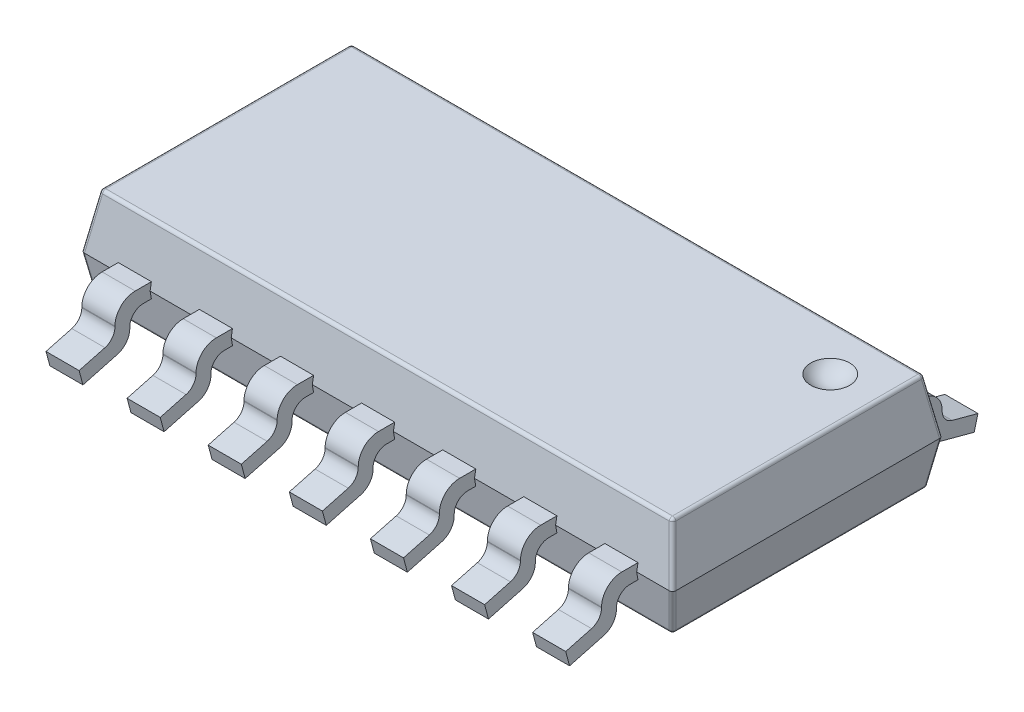
from build123d import *

# Parameters (mm, degrees)
BOSS_EXTRUDE1_DEPTH  = 4.375
CUT_EXTRUDE1_DEPTH   = 4.375
FILLET1_R            = 0.05
BOSS_EXTRUDE2_DEPTH  = 0.245
LPATTERN1_COUNT      = 4
LPATTERN1_PITCH      = 1.2
LPATTERN1_COL_COUNT  = 4
LPATTERN1_COL_PITCH  = 1.2
MIRROR1_COPY_1_DEPTH = 0.245
MIRROR1_COPY_2_DEPTH = 0.245
MIRROR1_COPY_3_DEPTH = 0.245
MIRROR1_COPY_4_DEPTH = 0.245
MIRROR1_COPY_5_DEPTH = 0.245
MIRROR1_COPY_6_DEPTH = 0.245


with BuildPart() as part:
    # Sketch3 → Boss-Extrude1 (new body, symmetric)
    with BuildSketch(Plane(origin=(0, 0, 0), x_dir=(0, 0, -1), z_dir=(1, 0, 0))):
        Polygon((-2, 0), (-1.885387463, -0.65), (1.885387463, -0.65), (2, 0), (1.858938415, 0.8), (-1.858938415, 0.8), align=None)
    extrude(amount=BOSS_EXTRUDE1_DEPTH, both=True)

    # Sketch4 → Cut-Extrude1 (cut, symmetric)
    with BuildSketch(Plane.XY):
        Polygon((-4.375, 0), (-4.233938415, 0.8), (-4.741857138, 0.8), (-4.741857138, -0.65), (-4.260387463, -0.65), align=None)
        Polygon((4.741857138, -0.65), (4.741857138, 0.8), (4.233938415, 0.8), (4.375, 0), (4.260387463, -0.65), align=None)
    extrude(amount=CUT_EXTRUDE1_DEPTH, both=True, mode=Mode.SUBTRACT)

    # Fillet1
    fillet1_edges = [part.edges().sort_by_distance(p)[0] for p in [
        (0, -0.65, -1.885387463),
        (0, -0.65, 1.885387463),
        (0, 0.8, 1.858938415),
        (0, 0.8, -1.858938415),
        (-4.317693731, -0.325, 1.942693731),
        (-4.317693731, -0.325, -1.942693731),
        (-4.260387463, -0.65, 0),
        (-4.304469208, 0.4, -1.929469208),
        (-4.233938415, 0.8, 0),
        (-4.304469208, 0.4, 1.929469208),
        (4.260387463, -0.65, 0),
        (4.317693731, -0.325, 1.942693731),
        (4.317693731, -0.325, -1.942693731),
        (4.304469208, 0.4, -1.929469208),
        (4.304469208, 0.4, 1.929469208),
        (4.233938415, 0.8, 0),
    ]]
    fillet(fillet1_edges, radius=FILLET1_R)

    # Sketch5 → Boss-Extrude2 (add, symmetric)
    with BuildSketch(Plane(origin=(0, 0, 0), x_dir=(0, 0, -1), z_dir=(1, 0, 0))):
        with BuildLine():
            Line((-1.980604032, 0.11), (-2, 0))
            Line((-2, 0), (-1.980604032, -0.11))
            Line((-1.980604032, -0.11), (-2.1, -0.11))
            ThreePointArc((-2.1, -0.11), (-2.241421356, -0.168578644), (-2.3, -0.31))
            Line((-2.3, -0.31), (-2.3, -0.329218636))
            ThreePointArc((-2.3, -0.329218636), (-2.351661665, -0.481408993), (-2.485295239, -0.570700092))
            Line((-2.485295239, -0.570700092), (-2.99305981, -0.706755199))
            Line((-2.99305981, -0.706755199), (-3.05, -0.494251518))
            Line((-3.05, -0.494251518), (-2.668236191, -0.391958213))
            ThreePointArc((-2.668236191, -0.391958213), (-2.561329332, -0.320525334), (-2.52, -0.198773048))
            Line((-2.52, -0.198773048), (-2.52, -0.19))
            ThreePointArc((-2.52, -0.19), (-2.432132034, 0.022132034), (-2.22, 0.11))
            Line((-2.22, 0.11), (-2.180725376, 0.11))
            Line((-2.180725376, 0.11), (-1.980604032, 0.11))
        make_face()
    boss_extrude2 = extrude(amount=BOSS_EXTRUDE2_DEPTH, both=True)

    # LPattern1: Boss-Extrude2 ×4
    with Locations(*[(i * LPATTERN1_PITCH, 0, 0) for i in range(1, LPATTERN1_COUNT)]):
        add(boss_extrude2)

    # LPattern1 col: Boss-Extrude2 ×4
    with Locations(*[(-i * LPATTERN1_COL_PITCH, 0, 0) for i in range(1, LPATTERN1_COL_COUNT)]):
        add(boss_extrude2)

    # Mirror1: Boss-Extrude2 across plane
    add(boss_extrude2.mirror(Plane.XY))

    # Mirror1 copy 1 sketch → Mirror1 copy 1 (add, symmetric)
    with BuildSketch(Plane(origin=(1.2, 0, 0), x_dir=(0, 0, 1), z_dir=(1, 0, 0))):
        with BuildLine():
            Line((-1.980604032, -0.11), (-2, 0))
            Line((-2, 0), (-1.980604032, 0.11))
            Line((-1.980604032, 0.11), (-2.1, 0.11))
            ThreePointArc((-2.1, 0.11), (-2.241421356, 0.168578644), (-2.3, 0.31))
            Line((-2.3, 0.31), (-2.3, 0.329218636))
            ThreePointArc((-2.3, 0.329218636), (-2.351661665, 0.481408993), (-2.485295239, 0.570700092))
            Line((-2.485295239, 0.570700092), (-2.99305981, 0.706755199))
            Line((-2.99305981, 0.706755199), (-3.05, 0.494251518))
            Line((-3.05, 0.494251518), (-2.668236191, 0.391958213))
            ThreePointArc((-2.668236191, 0.391958213), (-2.561329332, 0.320525334), (-2.52, 0.198773048))
            Line((-2.52, 0.198773048), (-2.52, 0.19))
            ThreePointArc((-2.52, 0.19), (-2.432132034, -0.022132034), (-2.22, -0.11))
            Line((-2.22, -0.11), (-2.180725376, -0.11))
            Line((-2.180725376, -0.11), (-1.980604032, -0.11))
        make_face()
    extrude(amount=MIRROR1_COPY_1_DEPTH, both=True)

    # Mirror1 copy 2 sketch → Mirror1 copy 2 (add, symmetric)
    with BuildSketch(Plane(origin=(2.4, 0, 0), x_dir=(0, 0, 1), z_dir=(1, 0, 0))):
        with BuildLine():
            Line((-1.980604032, -0.11), (-2, 0))
            Line((-2, 0), (-1.980604032, 0.11))
            Line((-1.980604032, 0.11), (-2.1, 0.11))
            ThreePointArc((-2.1, 0.11), (-2.241421356, 0.168578644), (-2.3, 0.31))
            Line((-2.3, 0.31), (-2.3, 0.329218636))
            ThreePointArc((-2.3, 0.329218636), (-2.351661665, 0.481408993), (-2.485295239, 0.570700092))
            Line((-2.485295239, 0.570700092), (-2.99305981, 0.706755199))
            Line((-2.99305981, 0.706755199), (-3.05, 0.494251518))
            Line((-3.05, 0.494251518), (-2.668236191, 0.391958213))
            ThreePointArc((-2.668236191, 0.391958213), (-2.561329332, 0.320525334), (-2.52, 0.198773048))
            Line((-2.52, 0.198773048), (-2.52, 0.19))
            ThreePointArc((-2.52, 0.19), (-2.432132034, -0.022132034), (-2.22, -0.11))
            Line((-2.22, -0.11), (-2.180725376, -0.11))
            Line((-2.180725376, -0.11), (-1.980604032, -0.11))
        make_face()
    extrude(amount=MIRROR1_COPY_2_DEPTH, both=True)

    # Mirror1 copy 3 sketch → Mirror1 copy 3 (add, symmetric)
    with BuildSketch(Plane(origin=(3.6, 0, 0), x_dir=(0, 0, 1), z_dir=(1, 0, 0))):
        with BuildLine():
            Line((-1.980604032, -0.11), (-2, 0))
            Line((-2, 0), (-1.980604032, 0.11))
            Line((-1.980604032, 0.11), (-2.1, 0.11))
            ThreePointArc((-2.1, 0.11), (-2.241421356, 0.168578644), (-2.3, 0.31))
            Line((-2.3, 0.31), (-2.3, 0.329218636))
            ThreePointArc((-2.3, 0.329218636), (-2.351661665, 0.481408993), (-2.485295239, 0.570700092))
            Line((-2.485295239, 0.570700092), (-2.99305981, 0.706755199))
            Line((-2.99305981, 0.706755199), (-3.05, 0.494251518))
            Line((-3.05, 0.494251518), (-2.668236191, 0.391958213))
            ThreePointArc((-2.668236191, 0.391958213), (-2.561329332, 0.320525334), (-2.52, 0.198773048))
            Line((-2.52, 0.198773048), (-2.52, 0.19))
            ThreePointArc((-2.52, 0.19), (-2.432132034, -0.022132034), (-2.22, -0.11))
            Line((-2.22, -0.11), (-2.180725376, -0.11))
            Line((-2.180725376, -0.11), (-1.980604032, -0.11))
        make_face()
    extrude(amount=MIRROR1_COPY_3_DEPTH, both=True)

    # Mirror1 copy 4 sketch → Mirror1 copy 4 (add, symmetric)
    with BuildSketch(Plane(origin=(-1.2, 0, 0), x_dir=(0, 0, 1), z_dir=(1, 0, 0))):
        with BuildLine():
            Line((-1.980604032, -0.11), (-2, 0))
            Line((-2, 0), (-1.980604032, 0.11))
            Line((-1.980604032, 0.11), (-2.1, 0.11))
            ThreePointArc((-2.1, 0.11), (-2.241421356, 0.168578644), (-2.3, 0.31))
            Line((-2.3, 0.31), (-2.3, 0.329218636))
            ThreePointArc((-2.3, 0.329218636), (-2.351661665, 0.481408993), (-2.485295239, 0.570700092))
            Line((-2.485295239, 0.570700092), (-2.99305981, 0.706755199))
            Line((-2.99305981, 0.706755199), (-3.05, 0.494251518))
            Line((-3.05, 0.494251518), (-2.668236191, 0.391958213))
            ThreePointArc((-2.668236191, 0.391958213), (-2.561329332, 0.320525334), (-2.52, 0.198773048))
            Line((-2.52, 0.198773048), (-2.52, 0.19))
            ThreePointArc((-2.52, 0.19), (-2.432132034, -0.022132034), (-2.22, -0.11))
            Line((-2.22, -0.11), (-2.180725376, -0.11))
            Line((-2.180725376, -0.11), (-1.980604032, -0.11))
        make_face()
    extrude(amount=MIRROR1_COPY_4_DEPTH, both=True)

    # Mirror1 copy 5 sketch → Mirror1 copy 5 (add, symmetric)
    with BuildSketch(Plane(origin=(-2.4, 0, 0), x_dir=(0, 0, 1), z_dir=(1, 0, 0))):
        with BuildLine():
            Line((-1.980604032, -0.11), (-2, 0))
            Line((-2, 0), (-1.980604032, 0.11))
            Line((-1.980604032, 0.11), (-2.1, 0.11))
            ThreePointArc((-2.1, 0.11), (-2.241421356, 0.168578644), (-2.3, 0.31))
            Line((-2.3, 0.31), (-2.3, 0.329218636))
            ThreePointArc((-2.3, 0.329218636), (-2.351661665, 0.481408993), (-2.485295239, 0.570700092))
            Line((-2.485295239, 0.570700092), (-2.99305981, 0.706755199))
            Line((-2.99305981, 0.706755199), (-3.05, 0.494251518))
            Line((-3.05, 0.494251518), (-2.668236191, 0.391958213))
            ThreePointArc((-2.668236191, 0.391958213), (-2.561329332, 0.320525334), (-2.52, 0.198773048))
            Line((-2.52, 0.198773048), (-2.52, 0.19))
            ThreePointArc((-2.52, 0.19), (-2.432132034, -0.022132034), (-2.22, -0.11))
            Line((-2.22, -0.11), (-2.180725376, -0.11))
            Line((-2.180725376, -0.11), (-1.980604032, -0.11))
        make_face()
    extrude(amount=MIRROR1_COPY_5_DEPTH, both=True)

    # Mirror1 copy 6 sketch → Mirror1 copy 6 (add, symmetric)
    with BuildSketch(Plane(origin=(-3.6, 0, 0), x_dir=(0, 0, 1), z_dir=(1, 0, 0))):
        with BuildLine():
            Line((-1.980604032, -0.11), (-2, 0))
            Line((-2, 0), (-1.980604032, 0.11))
            Line((-1.980604032, 0.11), (-2.1, 0.11))
            ThreePointArc((-2.1, 0.11), (-2.241421356, 0.168578644), (-2.3, 0.31))
            Line((-2.3, 0.31), (-2.3, 0.329218636))
            ThreePointArc((-2.3, 0.329218636), (-2.351661665, 0.481408993), (-2.485295239, 0.570700092))
            Line((-2.485295239, 0.570700092), (-2.99305981, 0.706755199))
            Line((-2.99305981, 0.706755199), (-3.05, 0.494251518))
            Line((-3.05, 0.494251518), (-2.668236191, 0.391958213))
            ThreePointArc((-2.668236191, 0.391958213), (-2.561329332, 0.320525334), (-2.52, 0.198773048))
            Line((-2.52, 0.198773048), (-2.52, 0.19))
            ThreePointArc((-2.52, 0.19), (-2.432132034, -0.022132034), (-2.22, -0.11))
            Line((-2.22, -0.11), (-2.180725376, -0.11))
            Line((-2.180725376, -0.11), (-1.980604032, -0.11))
        make_face()
    extrude(amount=MIRROR1_COPY_6_DEPTH, both=True)

    # Sketch6 → Cut-Revolve1 (revolve, cut)
    with BuildSketch(Plane(origin=(0, 1, 0), x_dir=(1, 0, 0), z_dir=(0, 1, 0))):
        with BuildLine():
            Line((3.191983434, 1.166983434), (3.891983434, 1.166983434))
            ThreePointArc((3.891983434, 1.166983434), (3.541983434, 1.516983434), (3.191983434, 1.166983434))
        make_face()
    revolve(axis=Axis((3.191983434, 1, -1.166983434), (1, 0, 0)), mode=Mode.SUBTRACT)


solid = part.part
